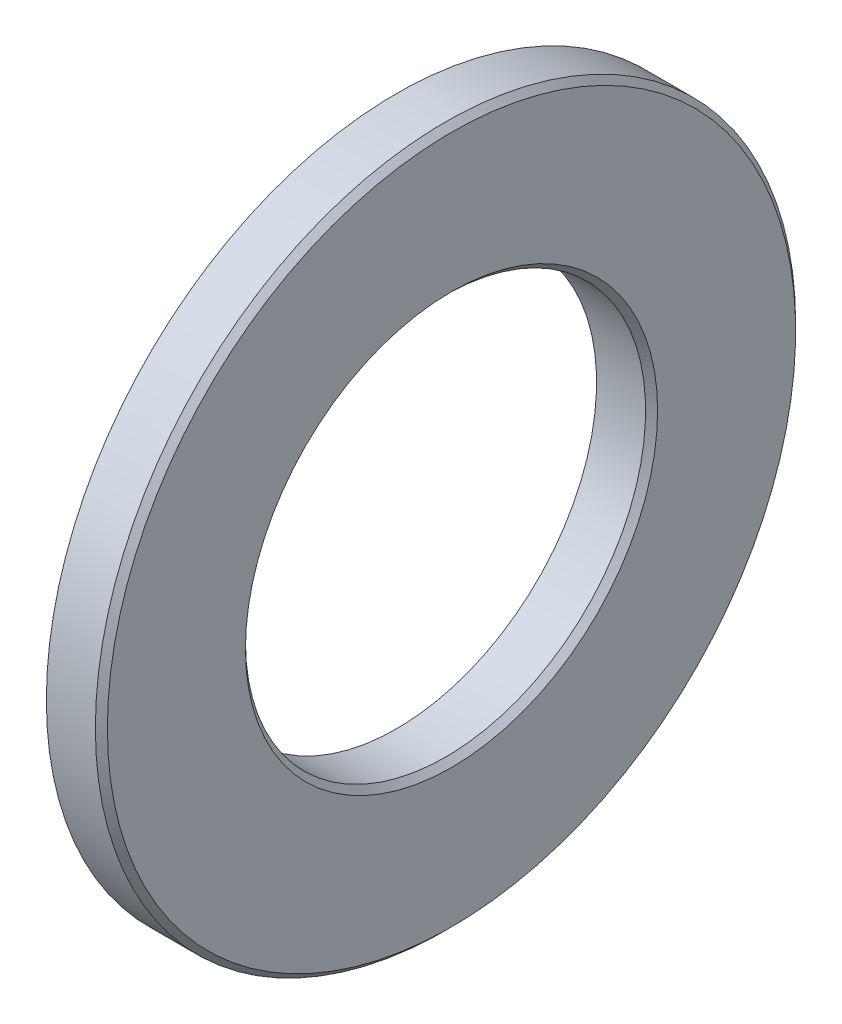
from build123d import *


with BuildPart() as part:
    # Sketch1 → Revolve1 (revolve)
    with BuildSketch(Plane.XY):
        Polygon((1, 10), (3.45, 10), (3.75, 10.3), (3.75, 17.2), (3.45, 17.5), (1, 17.5), align=None)
    revolve(axis=Axis((50, 0, 0), (-1, 0, 0)))


solid = part.part
